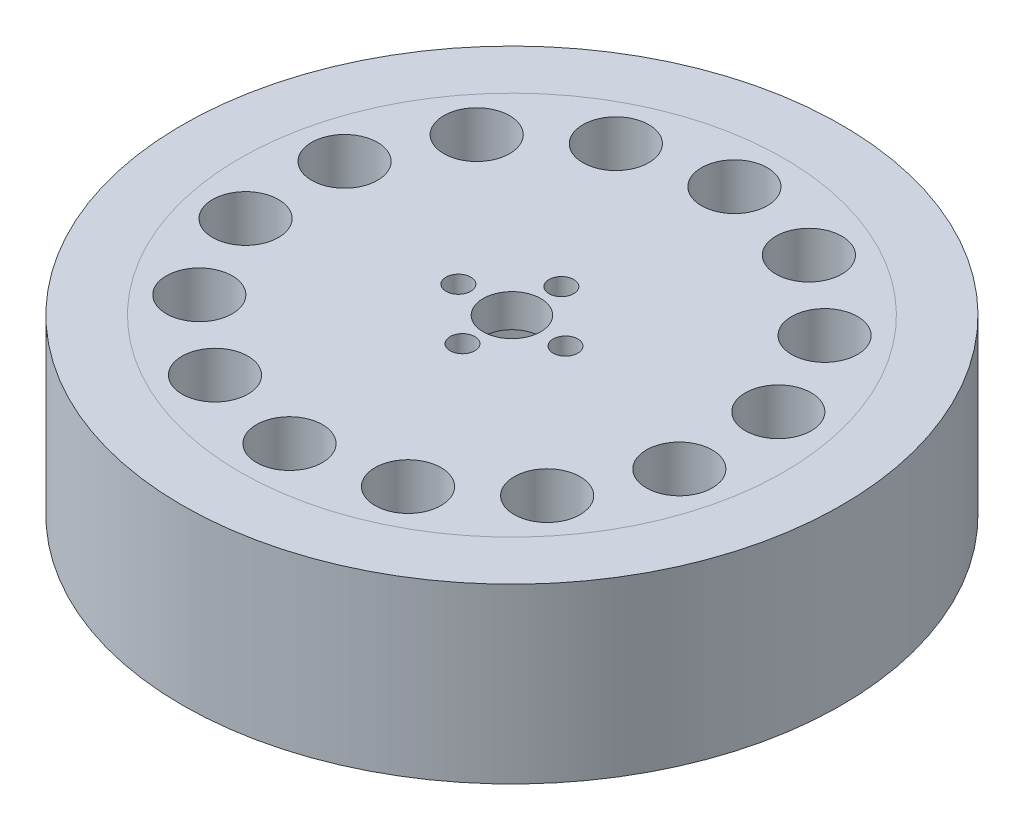
from build123d import *

# Parameters (mm, degrees)
SKETCH_1_R      = 33
SKETCH_1_R_2    = 21
SKETCH_1_R_3    = 4
EXTRUDE_1_DEPTH = 10.5
SKETCH_2_R      = 21
SKETCH_2_R_2    = 1.5
SKETCH_2_R_3    = 3.5
EXTRUDE_2_DEPTH = 4
SKETCH_3_R      = 40
SKETCH_3_R_2    = 33
EXTRUDE_3_DEPTH = 21


with BuildPart() as part:
    # 草图1 → 凸台-拉伸1 (new body, symmetric)
    with BuildSketch(Plane(origin=(0, 0, 0), x_dir=(1, 0, 0), z_dir=(0, 1, 0))):
        Circle(SKETCH_1_R)
        Circle(SKETCH_1_R_2, mode=Mode.SUBTRACT)
        with Locations((0, 27)):
            Circle(SKETCH_1_R_3, mode=Mode.SUBTRACT)
        with Locations((11.714860956, 24.326159433)):
            Circle(SKETCH_1_R_3, mode=Mode.SUBTRACT)
        with Locations((21.109450027, 16.83422465)):
            Circle(SKETCH_1_R_3, mode=Mode.SUBTRACT)
        with Locations((26.323053629, 6.008065217)):
            Circle(SKETCH_1_R_3, mode=Mode.SUBTRACT)
        with Locations((26.323053629, -6.008065217)):
            Circle(SKETCH_1_R_3, mode=Mode.SUBTRACT)
        with Locations((21.109450027, -16.83422465)):
            Circle(SKETCH_1_R_3, mode=Mode.SUBTRACT)
        with Locations((11.714860956, -24.326159433)):
            Circle(SKETCH_1_R_3, mode=Mode.SUBTRACT)
        with Locations((0, -27)):
            Circle(SKETCH_1_R_3, mode=Mode.SUBTRACT)
        with Locations((-11.714860956, -24.326159433)):
            Circle(SKETCH_1_R_3, mode=Mode.SUBTRACT)
        with Locations((-21.109450027, -16.83422465)):
            Circle(SKETCH_1_R_3, mode=Mode.SUBTRACT)
        with Locations((-26.323053629, -6.008065217)):
            Circle(SKETCH_1_R_3, mode=Mode.SUBTRACT)
        with Locations((-26.323053629, 6.008065217)):
            Circle(SKETCH_1_R_3, mode=Mode.SUBTRACT)
        with Locations((-21.109450027, 16.83422465)):
            Circle(SKETCH_1_R_3, mode=Mode.SUBTRACT)
        with Locations((-11.714860956, 24.326159433)):
            Circle(SKETCH_1_R_3, mode=Mode.SUBTRACT)
    extrude(amount=EXTRUDE_1_DEPTH, both=True)

    # 草图2 → 凸台-拉伸2 (add)
    with BuildSketch(Plane(origin=(0, 10.5, 0), x_dir=(1, 0, 0), z_dir=(0, 1, 0))):
        Circle(SKETCH_2_R)
        with Locations((0, 6)):
            Circle(SKETCH_2_R_2, mode=Mode.SUBTRACT)
        with Locations((0, -6)):
            Circle(SKETCH_2_R_2, mode=Mode.SUBTRACT)
        with Locations((-6.5, 0)):
            Circle(SKETCH_2_R_2, mode=Mode.SUBTRACT)
        with Locations((6.5, 0)):
            Circle(SKETCH_2_R_2, mode=Mode.SUBTRACT)
        Circle(SKETCH_2_R_3, mode=Mode.SUBTRACT)
    extrude(amount=-EXTRUDE_2_DEPTH)


with BuildPart() as body_2:
    # 草图3 → 凸台-拉伸3 (new body)
    with BuildSketch(Plane(origin=(0, 10.5, 0), x_dir=(1, 0, 0), z_dir=(0, 1, 0))):
        Circle(SKETCH_3_R)
        Circle(SKETCH_3_R_2, mode=Mode.SUBTRACT)
    extrude(amount=-EXTRUDE_3_DEPTH)


solid = Compound([part.part, body_2.part])
